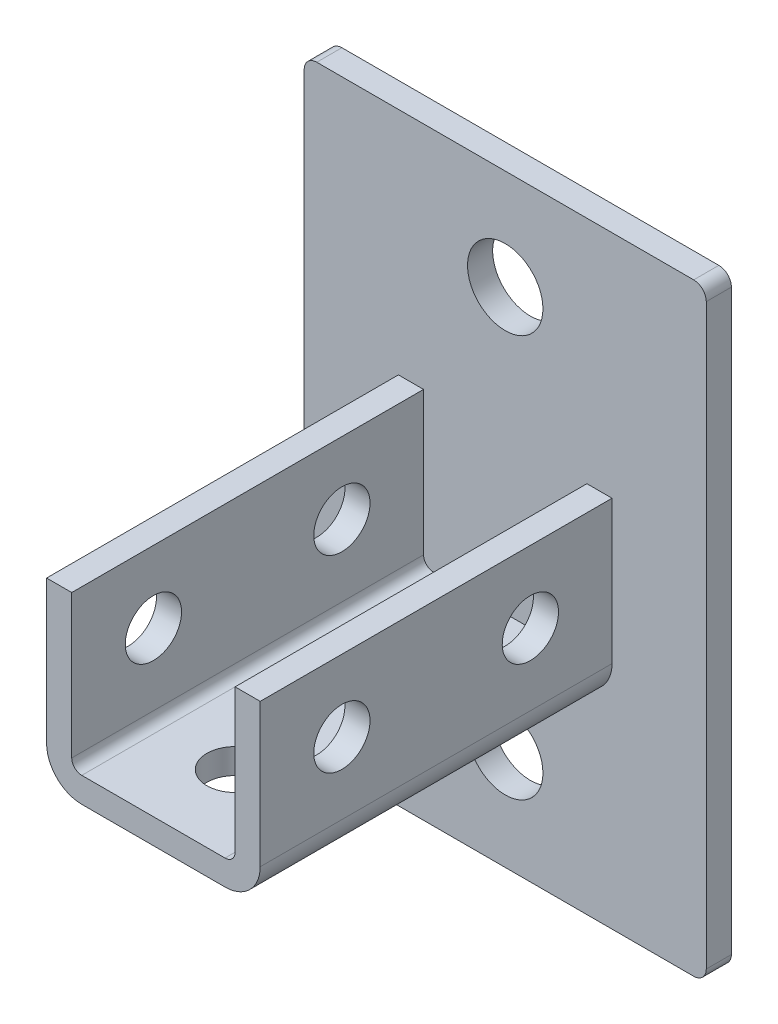
from build123d import *

# Parameters (mm, degrees)
SKETCH1_R           = 9.525
BOSS_EXTRUDE1_DEPTH = 6.35
EXTRUDE_THIN1_DEPTH = 88.9
SKETCH3_R           = 7.112
CUT_EXTRUDE1_DEPTH  = 77.2
CIRPATTERN1_COUNT   = 4


with BuildPart() as part:
    # Sketch1 → Boss-Extrude1 (new body)
    with BuildSketch(Plane.XY):
        with BuildLine():
            Line((-47.625, 76.2), (47.625, 76.2))
            ThreePointArc((47.625, 76.2), (49.87006403, 75.27006403), (50.8, 73.025))
            Line((50.8, 73.025), (50.8, -73.025))
            ThreePointArc((50.8, -73.025), (49.87006403, -75.27006403), (47.625, -76.2))
            Line((47.625, -76.2), (-47.625, -76.2))
            ThreePointArc((-47.625, -76.2), (-49.87006403, -75.27006403), (-50.8, -73.025))
            Line((-50.8, -73.025), (-50.8, 73.025))
            ThreePointArc((-50.8, 73.025), (-49.87006403, 75.27006403), (-47.625, 76.2))
        make_face()
        with Locations((0, 50.8)):
            Circle(SKETCH1_R, mode=Mode.SUBTRACT)
        with Locations((0, -50.8)):
            Circle(SKETCH1_R, mode=Mode.SUBTRACT)
    extrude(amount=BOSS_EXTRUDE1_DEPTH)

    # Sketch2 → Extrude-Thin1 (add)
    with BuildSketch(Plane.XY.offset(6.35)):
        with BuildLine():
            Line((-20.6375, 18.0975), (-20.6375, -18.0975))
            ThreePointArc((-20.6375, -18.0975), (-19.893551224, -19.893551224), (-18.0975, -20.6375))
            Line((-18.0975, -20.6375), (18.0975, -20.6375))
            ThreePointArc((18.0975, -20.6375), (19.893551224, -19.893551224), (20.6375, -18.0975))
            Line((20.6375, -18.0975), (20.6375, 18.0975))
            Line((20.6375, 18.0975), (26.9875, 18.0975))
            Line((26.9875, 18.0975), (26.9875, -18.0975))
            ThreePointArc((26.9875, -18.0975), (24.383679285, -24.383679285), (18.0975, -26.9875))
            Line((18.0975, -26.9875), (-18.0975, -26.9875))
            ThreePointArc((-18.0975, -26.9875), (-24.383679285, -24.383679285), (-26.9875, -18.0975))
            Line((-26.9875, -18.0975), (-26.9875, 18.0975))
            Line((-26.9875, 18.0975), (-20.6375, 18.0975))
        make_face()
    extrude(amount=EXTRUDE_THIN1_DEPTH)

    # Sketch3 → Cut-Extrude1 (cut, through all)
    with BuildSketch(Plane.XZ):
        with Locations((0, 74.6125)):
            Circle(SKETCH3_R)
        with Locations((0, 26.9875)):
            Circle(SKETCH3_R)
    cut_extrude1 = extrude(amount=CUT_EXTRUDE1_DEPTH, mode=Mode.SUBTRACT)

    # CirPattern1: Cut-Extrude1 ×4 about axis, 1 skipped
    cirpattern1_axis = Axis((0, 0, 74.6125), (0, 0, -1))
    add([cut_extrude1.rotate(cirpattern1_axis, i * 360 / CIRPATTERN1_COUNT) for i in range(1, CIRPATTERN1_COUNT) if i not in (2,)], mode=Mode.SUBTRACT)


solid = part.part
